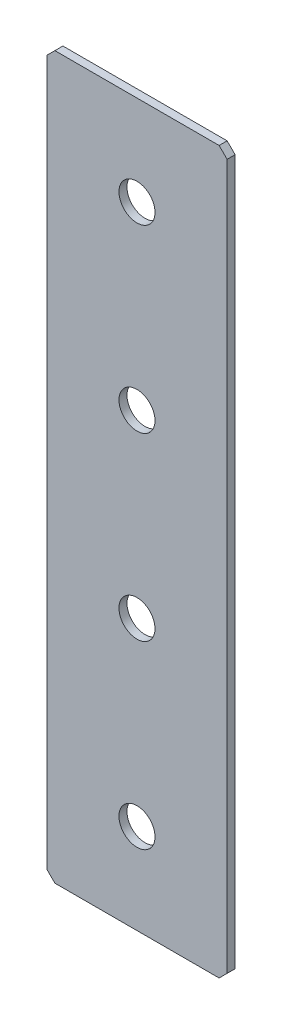
from build123d import *

# Parameters (mm, degrees)
SKETCH_1_W        = 45
SKETCH_1_H        = 180
EXTRUDE_1_DEPTH   = 2
CHAMFER_1_SIZE    = 2
HOLE_WIZARD_M81_D = 9


with BuildPart() as part:
    # Эскиз1 → Бобышка-Вытянуть1 (new body)
    with BuildSketch(Plane.XY):
        Rectangle(SKETCH_1_W, SKETCH_1_H)
    extrude(amount=EXTRUDE_1_DEPTH)

    # Фаска1
    chamfer_1_edges = [part.edges().sort_by_distance(p)[0] for p in [
        (22.5, -90, 1),
        (-22.5, -90, 1),
        (-22.5, 90, 1),
        (22.5, 90, 1),
    ]]
    chamfer(chamfer_1_edges, length=CHAMFER_1_SIZE)

    # Отверстие с зазором M81 (through all)
    with Locations(Plane.XY.offset(2)):
        with Locations((0, 67.5), (0, 22.5), (0, -22.5), (0, -67.5)):
            Hole(HOLE_WIZARD_M81_D / 2)


solid = part.part
